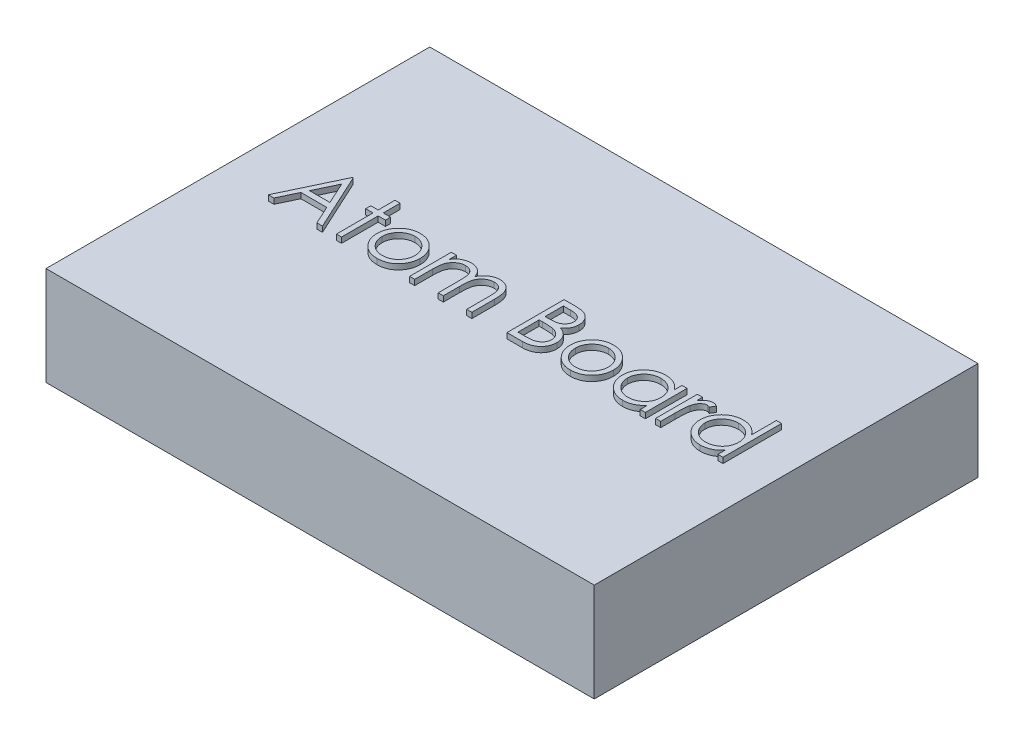
from build123d import *

# Parameters (mm, degrees)
SKETCH1_W           = 254
SKETCH1_H           = 177.8
BOSS_EXTRUDE1_DEPTH = 45.72
BOSS_EXTRUDE2_DEPTH = 2.54


with BuildPart() as part:
    # Sketch1 → Boss-Extrude1 (new body)
    with BuildSketch(Plane(origin=(0, 0, 0), x_dir=(1, 0, 0), z_dir=(0, 1, 0))):
        Rectangle(SKETCH1_W, SKETCH1_H)
    extrude(amount=BOSS_EXTRUDE1_DEPTH)

    # Sketch2 → Boss-Extrude2 (add)
    with BuildSketch(Plane(origin=(0, 45.72, 0), x_dir=(1, 0, 0), z_dir=(0, 1, 0))):
        Polygon((-89.677431312, 16.12080244), (-77.46589285, -10.337530894), (-80.047064392, -10.337530894), (-83.958572805, -1.857295851), (-95.952805244, -1.857295851), (-99.975616742, -10.337530894), (-102.567388577, -10.337530894), (-90.016640714, 16.12080244), align=None)
        Polygon((-89.873536747, 10.963759504), (-94.664869546, 0.856379363), (-85.209407474, 0.856379363), align=None, mode=Mode.SUBTRACT)
        Polygon((-71.020914218, 16.799221243), (-68.646448406, 16.799221243), (-68.646448406, 8.997405004), (-65.254354389, 8.997405004), (-65.254354389, 6.622939192), (-68.646448406, 6.622939192), (-68.646448406, -10.337530894), (-71.020914218, -10.337530894), (-71.020914218, 6.622939192), (-74.413008235, 6.622939192), (-74.413008235, 8.997405004), (-71.020914218, 8.997405004), align=None)
        with BuildLine():
            add(Edge.make_bspline(
                [(-51.844982728, 9.336614406), (-51.482191558, 9.328889395), (-50.770846736, 9.313742538), (-49.729084741, 9.151855595), (-48.734666154, 8.904301114), (-47.78378244, 8.562069663), (-46.888611635, 8.103343013), (-46.03611473, 7.555963253), (-45.228629008, 6.907487694), (-44.744645394, 6.405852296), (-44.498979122, 6.151226118)],
                knots=[0, 0, 0, 0, 0.001087577, 0.002132472, 0.003154425, 0.004158785, 0.005156692, 0.006165239, 0.007194137, 0.008254762, 0.008254762, 0.008254762, 0.008254762], degree=3))
            add(Edge.make_bspline(
                [(-44.498979122, 6.151226118), (-44.287448874, 5.907703725), (-43.868482071, 5.425371769), (-43.331259078, 4.6432966), (-42.868453236, 3.833368458), (-42.497560614, 2.98483212), (-42.205120257, 2.105095022), (-41.997492672, 1.19113339), (-41.873993223, 0.244965647), (-41.857339842, -0.397622891), (-41.848905671, -0.723064414)],
                knots=[0, 0, 0, 0, 0.000967026, 0.001915338, 0.002840969, 0.003761746, 0.004688606, 0.005618204, 0.006569473, 0.007545621, 0.007545621, 0.007545621, 0.007545621], degree=3))
            add(Edge.make_bspline(
                [(-41.848905671, -0.723064414), (-41.856324114, -1.050392231), (-41.870983303, -1.697207262), (-42.009652308, -2.649853659), (-42.225333731, -3.57358833), (-42.534002983, -4.464543932), (-42.929805357, -5.325443877), (-43.412788531, -6.15252797), (-43.986341827, -6.947428025), (-44.636491088, -7.703394302), (-45.355038009, -8.400126997), (-46.134546988, -9.007370464), (-46.959699505, -9.527628416), (-47.841467711, -9.946701319), (-48.771799308, -10.27712584), (-49.752700954, -10.509203345), (-50.782648807, -10.649520835), (-51.485890301, -10.667539514), (-51.844982728, -10.676740295)],
                knots=[0, 0, 0, 0, 0.000981444, 0.001939378, 0.002881702, 0.003823698, 0.004762841, 0.005720057, 0.006692313, 0.007699508, 0.008707832, 0.009689605, 0.010658735, 0.011628329, 0.012612345, 0.013615068, 0.014647237, 0.015724223, 0.015724223, 0.015724223, 0.015724223], degree=3))
            add(Edge.make_bspline(
                [(-51.844982728, -10.676740295), (-52.205834476, -10.667508633), (-52.912580856, -10.649427957), (-53.946164172, -10.509748498), (-54.928823791, -10.277232797), (-55.860373316, -9.945615441), (-56.745932576, -9.527615021), (-57.575866213, -9.00894332), (-58.356008432, -8.399946908), (-59.074707362, -7.703443099), (-59.724815866, -6.947415453), (-60.298379679, -6.152531233), (-60.781360121, -5.325443027), (-61.17716321, -4.464544158), (-61.485832272, -3.573588269), (-61.701513746, -2.649853675), (-61.840182737, -1.697207258), (-61.854841928, -1.050392229), (-61.862260372, -0.723064414)],
                knots=[0, 0, 0, 0, 0.001082282, 0.002119703, 0.003122426, 0.004106442, 0.005080819, 0.006054446, 0.007036219, 0.008044543, 0.009051738, 0.010023994, 0.01098121, 0.011920353, 0.012862349, 0.013804673, 0.014762608, 0.015744051, 0.015744051, 0.015744051, 0.015744051], degree=3))
            add(Edge.make_bspline(
                [(-61.862260372, -0.723064414), (-61.85376868, -0.399391716), (-61.836956591, 0.2414246), (-61.713581314, 1.18581369), (-61.506763655, 2.098228476), (-61.213972741, 2.974569872), (-60.839661477, 3.819387751), (-60.383358883, 4.631317128), (-59.840655887, 5.409855858), (-59.42335542, 5.891564439), (-59.212186921, 6.135325677)],
                knots=[0, 0, 0, 0, 0.000970853, 0.001922123, 0.002851721, 0.00377355, 0.004689479, 0.005619727, 0.006563689, 0.007530715, 0.007530715, 0.007530715, 0.007530715], degree=3))
            add(Edge.make_bspline(
                [(-59.212186921, 6.135325677), (-58.966891024, 6.392160039), (-58.484473482, 6.897270005), (-57.672968219, 7.543855157), (-56.8225685, 8.102625477), (-55.91750507, 8.552237344), (-54.967402513, 8.906314234), (-53.967888001, 9.152494021), (-52.92259095, 9.313159264), (-52.207765243, 9.328718108), (-51.844982728, 9.336614406)],
                knots=[0, 0, 0, 0, 0.001064367, 0.002093264, 0.00310469, 0.004112067, 0.005118257, 0.00614021, 0.007195592, 0.008283169, 0.008283169, 0.008283169, 0.008283169], degree=3))
        make_face()
        with BuildLine():
            add(Edge.make_bspline(
                [(-51.855583021, 6.962148594), (-52.112135202, 6.95485674), (-52.618616711, 6.940461271), (-53.364133809, 6.830969848), (-54.081836163, 6.657497645), (-54.773085402, 6.411026505), (-55.435550455, 6.092778876), (-56.06986558, 5.701888296), (-56.677896525, 5.243532018), (-57.247749028, 4.718427298), (-57.770734364, 4.144818232), (-58.227919068, 3.533643138), (-58.616668384, 2.894815402), (-58.940519585, 2.22767071), (-59.181722733, 1.525448296), (-59.356899749, 0.796100667), (-59.466287876, 0.038141864), (-59.480548, -0.477122977), (-59.48779456, -0.738964855)],
                knots=[0, 0, 0, 0, 0.000769416, 0.00151897, 0.002255557, 0.002981445, 0.003716333, 0.004456269, 0.005213132, 0.005997142, 0.006777579, 0.007538681, 0.008283139, 0.009018027, 0.009758911, 0.010505799, 0.011265848, 0.012051147, 0.012051147, 0.012051147, 0.012051147], degree=3))
            add(Edge.make_bspline(
                [(-59.48779456, -0.738964855), (-59.475647738, -1.077268869), (-59.451538569, -1.748739078), (-59.255480532, -2.737608874), (-58.927500916, -3.686947875), (-58.48460898, -4.591190793), (-57.929692922, -5.427820514), (-57.275891882, -6.173729949), (-56.530222719, -6.817694119), (-55.701574176, -7.352007654), (-54.806871891, -7.776548665), (-53.85999375, -8.077409969), (-52.872412313, -8.272987644), (-52.1974925, -8.292426765), (-51.855583021, -8.302274483)],
                knots=[0, 0, 0, 0, 0.001014324, 0.002013244, 0.003010531, 0.004020303, 0.005025781, 0.006013502, 0.006986782, 0.007971769, 0.008962783, 0.009948354, 0.010946274, 0.011970863, 0.011970863, 0.011970863, 0.011970863], degree=3))
            add(Edge.make_bspline(
                [(-51.855583021, -8.302274483), (-51.513693209, -8.292369388), (-50.838812215, -8.272817006), (-49.852602962, -8.078394976), (-48.908312817, -7.775230398), (-48.014539828, -7.352485121), (-47.186268481, -6.815665081), (-46.435236433, -6.177366278), (-45.787017765, -5.425844902), (-45.232650633, -4.59008263), (-44.782505614, -3.688349731), (-44.456061172, -2.73743366), (-44.259531802, -1.7487837), (-44.235486252, -1.077283819), (-44.223371483, -0.738964855)],
                knots=[0, 0, 0, 0, 0.001024588, 0.002022509, 0.003003036, 0.00399405, 0.004979037, 0.005956336, 0.006940566, 0.007946044, 0.008958164, 0.009955451, 0.010954371, 0.011968695, 0.011968695, 0.011968695, 0.011968695], degree=3))
            add(Edge.make_bspline(
                [(-44.223371483, -0.738964855), (-44.230615548, -0.477121412), (-44.244870762, 0.038146508), (-44.3542946, 0.796082913), (-44.529339453, 1.525513435), (-44.771029655, 2.227430365), (-45.093473689, 2.896542749), (-45.489719684, 3.531767471), (-45.945037554, 4.146935408), (-46.474333647, 4.71657305), (-47.043591325, 5.243736719), (-47.651868697, 5.702066032), (-48.285243237, 6.09106095), (-48.945783714, 6.413748602), (-49.637121576, 6.655255282), (-50.353818326, 6.831971485), (-51.096154568, 6.939998566), (-51.600821145, 6.954718029), (-51.855583021, 6.962148594)],
                knots=[0, 0, 0, 0, 0.000785299, 0.001545348, 0.002292236, 0.00303312, 0.003768008, 0.004515235, 0.005276337, 0.006060346, 0.006844356, 0.00760122, 0.008341156, 0.009071269, 0.009802151, 0.010533591, 0.011283145, 0.012047267, 0.012047267, 0.012047267, 0.012047267], degree=3))
        make_face(mode=Mode.SUBTRACT)
        with BuildLine():
            Line((-37.099974047, 8.997405004), (-34.725508235, 8.997405004))
            Line((-34.725508235, 8.997405004), (-34.725508235, 5.637111868))
            add(Edge.make_bspline(
                [(-34.725508235, 5.637111868), (-34.511695042, 5.931083619), (-34.102008467, 6.494361678), (-33.430226451, 7.236633469), (-32.759121315, 7.866554638), (-32.275815393, 8.197229918), (-32.043633903, 8.356087229)],
                knots=[0, 0, 0, 0, 0.001089718, 0.002088005, 0.002999646, 0.003842519, 0.003842519, 0.003842519, 0.003842519], degree=3))
            add(Edge.make_bspline(
                [(-32.043633903, 8.356087229), (-31.727156992, 8.507318264), (-31.099732393, 8.80713815), (-30.106265633, 9.111284697), (-29.089701167, 9.298194689), (-28.403234312, 9.323756262), (-28.057923433, 9.336614406)],
                knots=[0, 0, 0, 0, 0.001051007, 0.002083652, 0.003106677, 0.00414216, 0.00414216, 0.00414216, 0.00414216], degree=3))
            add(Edge.make_bspline(
                [(-28.057923433, 9.336614406), (-27.82438709, 9.328712505), (-27.362231224, 9.313075069), (-26.677458638, 9.211323612), (-26.01328937, 9.035442424), (-25.373647601, 8.790458486), (-24.770997228, 8.493772222), (-24.218477697, 8.145658359), (-23.722389933, 7.754853086), (-23.282984664, 7.303708772), (-22.887855722, 6.779557104), (-22.524402536, 6.168261889), (-22.188569086, 5.456096832), (-22.002443715, 4.939278338), (-21.90445288, 4.667184985)],
                knots=[0, 0, 0, 0, 0.000700602, 0.001386455, 0.002071672, 0.002757769, 0.003438049, 0.00408358, 0.004713495, 0.005328175, 0.005967387, 0.0066782, 0.007458204, 0.008325438, 0.008325438, 0.008325438, 0.008325438], degree=3))
            add(Edge.make_bspline(
                [(-21.90445288, 4.667184985), (-21.800802349, 4.854089821), (-21.59683266, 5.221892291), (-21.254343618, 5.742427964), (-20.89550968, 6.22931264), (-20.517272738, 6.682932634), (-20.120967826, 7.101047858), (-19.704729859, 7.485040686), (-19.270928238, 7.836560159), (-18.6677369, 8.247217376), (-17.882963023, 8.683410831), (-16.893511204, 9.061602044), (-15.86428074, 9.295313253), (-15.165646949, 9.322756387), (-14.812856325, 9.336614406)],
                knots=[0, 0, 0, 0, 0.000640967, 0.001261334, 0.001867685, 0.002454687, 0.003032038, 0.003594653, 0.004152555, 0.004705322, 0.005782283, 0.006837492, 0.007874006, 0.008931342, 0.008931342, 0.008931342, 0.008931342], degree=3))
            add(Edge.make_bspline(
                [(-14.812856325, 9.336614406), (-14.488692886, 9.324388986), (-13.854273561, 9.300462653), (-12.930671612, 9.112582229), (-12.069325822, 8.78995954), (-11.271969354, 8.349740978), (-10.552606479, 7.796541199), (-9.92731057, 7.138342248), (-9.399879847, 6.3797998), (-9.055327035, 5.666241314), (-8.821622359, 5.036265882), (-8.677528504, 4.499492132), (-8.550228428, 3.908703607), (-8.444536872, 3.263193892), (-8.367289484, 2.560682746), (-8.31005848, 1.802319815), (-8.271322924, 0.987515697), (-8.26858583, 0.425347928), (-8.267174902, 0.135559384)],
                knots=[0, 0, 0, 0, 0.00097201, 0.001902318, 0.002812972, 0.003721588, 0.004624808, 0.005524554, 0.006434653, 0.007385169, 0.007893237, 0.008448742, 0.009050653, 0.009705902, 0.010410024, 0.011170184, 0.011987249, 0.012856538, 0.012856538, 0.012856538, 0.012856538], degree=3))
            Line((-8.267174902, 0.135559384), (-8.267174902, -10.337530894))
            Line((-8.267174902, -10.337530894), (-10.641640714, -10.337530894))
            Line((-10.641640714, -10.337530894), (-10.641640714, 0.146159678))
            add(Edge.make_bspline(
                [(-10.641640714, 0.146159678), (-10.642229472, 0.393511636), (-10.643360976, 0.86888448), (-10.663723548, 1.551150034), (-10.702090505, 2.17305964), (-10.746953548, 2.733765306), (-10.809272821, 3.2345746), (-10.889750996, 3.674481574), (-10.975004885, 4.056946695), (-11.116640056, 4.480930507), (-11.343031856, 4.948639837), (-11.687878283, 5.453038297), (-12.122324919, 5.892101488), (-12.623976103, 6.273239955), (-13.195086369, 6.583132361), (-13.824528026, 6.804445053), (-14.508393178, 6.941445384), (-14.981791638, 6.955098002), (-15.226267784, 6.962148594)],
                knots=[0, 0, 0, 0, 0.000742039, 0.001426087, 0.002047313, 0.00261115, 0.003113407, 0.003560446, 0.003952549, 0.00428776, 0.00489937, 0.005505096, 0.006112281, 0.006744066, 0.00738914, 0.008052993, 0.008739029, 0.009471678, 0.009471678, 0.009471678, 0.009471678], degree=3))
            add(Edge.make_bspline(
                [(-15.226267784, 6.962148594), (-15.526153748, 6.951443118), (-16.118842422, 6.930285029), (-16.9839958, 6.714280156), (-17.815324318, 6.388613975), (-18.588022049, 5.916654329), (-19.298827371, 5.351138721), (-19.910389656, 4.678722134), (-20.415609155, 3.918007806), (-20.757707663, 3.213863092), (-20.973829167, 2.581361939), (-21.116529661, 2.028780615), (-21.227529108, 1.400723524), (-21.331627751, 0.701410945), (-21.399570695, -0.073970776), (-21.4613197, -0.921834879), (-21.490203604, -1.844731477), (-21.494243857, -2.484468944), (-21.496341568, -2.81662244)],
                knots=[0, 0, 0, 0, 0.00089798, 0.00177475, 0.002659557, 0.003567616, 0.004479796, 0.005376461, 0.00628198, 0.007211246, 0.007715763, 0.008285251, 0.008921445, 0.009628275, 0.010405646, 0.011255671, 0.012178445, 0.013174929, 0.013174929, 0.013174929, 0.013174929], degree=3))
            Line((-21.496341568, -2.81662244), (-21.496341568, -10.337530894))
            Line((-21.496341568, -10.337530894), (-23.87080738, -10.337530894))
            Line((-23.87080738, -10.337530894), (-23.87080738, -0.505758391))
            add(Edge.make_bspline(
                [(-23.87080738, -0.505758391), (-23.871407841, -0.228374374), (-23.872563066, 0.305284594), (-23.892794751, 1.070562973), (-23.931247188, 1.76665209), (-23.975701334, 2.392742918), (-24.039656255, 2.947697606), (-24.11230148, 3.434491312), (-24.198091572, 3.851903656), (-24.340134152, 4.309734006), (-24.557201859, 4.814112412), (-24.906363125, 5.351904656), (-25.341849, 5.822621821), (-25.852652645, 6.224476646), (-26.427219409, 6.55665332), (-27.062093927, 6.795985967), (-27.751559637, 6.935264824), (-28.226885152, 6.95301834), (-28.471334891, 6.962148594)],
                knots=[0, 0, 0, 0, 0.00083214, 0.001600954, 0.002296263, 0.002923497, 0.003483635, 0.003971623, 0.00439992, 0.004760369, 0.00540831, 0.006040451, 0.006674367, 0.007323327, 0.00798336, 0.008657667, 0.00934994, 0.010082914, 0.010082914, 0.010082914, 0.010082914], degree=3))
            add(Edge.make_bspline(
                [(-28.471334891, 6.962148594), (-28.758719347, 6.950579045), (-29.331466361, 6.927521345), (-30.172856251, 6.719980108), (-30.985396835, 6.394889781), (-31.756125808, 5.943889958), (-32.464257763, 5.385248114), (-33.084201212, 4.72821289), (-33.605373875, 3.980961267), (-33.951084619, 3.28424141), (-34.174079036, 2.667586296), (-34.322210435, 2.143326156), (-34.449509988, 1.561240946), (-34.544110033, 0.919534809), (-34.635432222, 0.222387252), (-34.679506582, -0.533674664), (-34.722380891, -1.348002351), (-34.724440217, -1.910223378), (-34.725508235, -2.201805399)],
                knots=[0, 0, 0, 0, 0.000860976, 0.001715895, 0.002583971, 0.003479382, 0.004384948, 0.005281049, 0.00617942, 0.007108579, 0.007604872, 0.008145072, 0.008741803, 0.009390979, 0.010090458, 0.01085023, 0.011662001, 0.012536589, 0.012536589, 0.012536589, 0.012536589], degree=3))
            Line((-34.725508235, -2.201805399), (-34.725508235, -10.337530894))
            Line((-34.725508235, -10.337530894), (-37.099974047, -10.337530894))
            Line((-37.099974047, -10.337530894), (-37.099974047, 8.997405004))
        make_face()
        with BuildLine():
            Line((8.01487638, 16.12080244), (13.177219463, 16.12080244))
            add(Edge.make_bspline(
                [(13.177219463, 16.12080244), (13.429922839, 16.11947385), (13.919724876, 16.116898714), (14.63197899, 16.076960758), (15.299097975, 16.022504444), (15.921275302, 15.936098387), (16.498223468, 15.831839119), (17.031681202, 15.705581342), (17.519952147, 15.55418968), (18.102887714, 15.313446958), (18.767526044, 14.955706341), (19.48718056, 14.427079687), (20.102557846, 13.780494996), (20.633132982, 13.051132065), (21.054962874, 12.248796171), (21.360135538, 11.392610637), (21.553340906, 10.493618898), (21.573210617, 9.876435351), (21.583252449, 9.564520722)],
                knots=[0, 0, 0, 0, 0.000757995, 0.001469183, 0.002139542, 0.002765431, 0.003352791, 0.003897857, 0.004409122, 0.004884513, 0.005788044, 0.006666814, 0.007551415, 0.008454682, 0.009365073, 0.010260312, 0.011175044, 0.01210969, 0.01210969, 0.01210969, 0.01210969], degree=3))
            add(Edge.make_bspline(
                [(21.583252449, 9.564520722), (21.574988238, 9.272325807), (21.558748284, 8.698135244), (21.403454806, 7.85831668), (21.160335467, 7.058887823), (20.822385072, 6.302766219), (20.383161648, 5.60703593), (19.862625549, 4.966084573), (19.234604482, 4.407049797), (18.764075227, 4.094517141), (18.525067686, 3.935764713)],
                knots=[0, 0, 0, 0, 0.000875824, 0.001721077, 0.002552643, 0.003378174, 0.0041973, 0.005014365, 0.005847584, 0.006707745, 0.006707745, 0.006707745, 0.006707745], degree=3))
            add(Edge.make_bspline(
                [(18.525067686, 3.935764713), (18.825637586, 3.82036859), (19.400702259, 3.599587221), (20.192078663, 3.209247701), (20.873908741, 2.784688891), (21.451434785, 2.321049309), (21.945356343, 1.82129818), (22.376649413, 1.278107733), (22.74465742, 0.684392123), (23.059987259, 0.046341588), (23.306040355, -0.629528739), (23.490310585, -1.336879248), (23.595897849, -2.073173505), (23.610923471, -2.574259408), (23.618508859, -2.827222734)],
                knots=[0, 0, 0, 0, 0.000965515, 0.001847268, 0.002642803, 0.003370391, 0.004063739, 0.004746636, 0.005446657, 0.006155391, 0.006878099, 0.007600554, 0.008344861, 0.00910369, 0.00910369, 0.00910369, 0.00910369], degree=3))
            add(Edge.make_bspline(
                [(23.618508859, -2.827222734), (23.611124368, -3.085508017), (23.596595176, -3.593691548), (23.489401341, -4.340233339), (23.307903925, -5.053662995), (23.057901807, -5.738595031), (22.731615262, -6.393704381), (22.334528865, -7.019733222), (21.861064069, -7.610391554), (21.331422143, -8.172242753), (20.732238067, -8.677429002), (20.085779681, -9.127339404), (19.383905715, -9.497348326), (18.638143618, -9.808165869), (17.840127657, -10.045589334), (16.99344128, -10.211691529), (16.098814712, -10.323610559), (15.484907665, -10.332812049), (15.170074698, -10.337530894)],
                knots=[0, 0, 0, 0, 0.00077471, 0.001524264, 0.002256989, 0.002979697, 0.003707382, 0.004448437, 0.005199208, 0.005975222, 0.006761093, 0.007546159, 0.008333387, 0.009136565, 0.009966592, 0.010826213, 0.011722926, 0.012666888, 0.012666888, 0.012666888, 0.012666888], degree=3))
            Line((15.170074698, -10.337530894), (8.01487638, -10.337530894))
            Line((8.01487638, -10.337530894), (8.01487638, 16.12080244))
        make_face()
        with BuildLine():
            Line((10.389342192, 13.407127226), (10.389342192, 4.926892183))
            Line((10.389342192, 4.926892183), (11.98468641, 4.926892183))
            add(Edge.make_bspline(
                [(11.98468641, 4.926892183), (12.217888613, 4.929915411), (12.668482793, 4.935756902), (13.321020106, 4.952490037), (13.926727089, 4.999344294), (14.484558208, 5.046185085), (14.993635017, 5.12234417), (15.452829684, 5.212998909), (15.869348839, 5.308875632), (16.349677547, 5.471930682), (16.894514717, 5.712910726), (17.475336397, 6.086894249), (17.987376732, 6.5323343), (18.419760235, 7.046313594), (18.773632661, 7.612266309), (19.019420865, 8.221162369), (19.186087834, 8.857826463), (19.201142863, 9.294904921), (19.208786637, 9.5168194)],
                knots=[0, 0, 0, 0, 0.0006997, 0.001351962, 0.001957665, 0.002521975, 0.003030927, 0.003500761, 0.003926261, 0.004311753, 0.005021042, 0.005707631, 0.006376249, 0.007049451, 0.007715774, 0.008369328, 0.009013356, 0.009677589, 0.009677589, 0.009677589, 0.009677589], degree=3))
            add(Edge.make_bspline(
                [(19.208786637, 9.5168194), (19.204808965, 9.663668983), (19.197006328, 9.951730474), (19.133103386, 10.371657139), (19.024491365, 10.76659503), (18.884985695, 11.14195646), (18.690035489, 11.486004375), (18.460502165, 11.810634485), (18.183175816, 12.104791572), (17.867510417, 12.37972766), (17.504588089, 12.623480936), (17.094625348, 12.836967657), (16.632075646, 13.0088771), (16.124734421, 13.159433729), (15.564792271, 13.265178569), (14.958710826, 13.35327263), (14.301525747, 13.398121335), (13.846857413, 13.404058304), (13.611831509, 13.407127226)],
                knots=[0, 0, 0, 0, 0.000440423, 0.000863937, 0.00127022, 0.001667873, 0.002061692, 0.002452935, 0.002857971, 0.003271315, 0.003706444, 0.004166336, 0.004654554, 0.005184569, 0.005752106, 0.006362244, 0.007021192, 0.00772629, 0.00772629, 0.00772629, 0.00772629], degree=3))
            Line((13.611831509, 13.407127226), (10.389342192, 13.407127226))
        make_face(mode=Mode.SUBTRACT)
        with BuildLine():
            Line((10.389342192, 2.21321697), (10.389342192, -7.62385568))
            Line((10.389342192, -7.62385568), (13.770835916, -7.62385568))
            add(Edge.make_bspline(
                [(13.770835916, -7.62385568), (14.012883748, -7.620954732), (14.479399036, -7.615363538), (15.152961907, -7.597110656), (15.777250846, -7.555591667), (16.349417111, -7.49023316), (16.875638985, -7.41933655), (17.349603764, -7.324001272), (17.7751535, -7.214774011), (18.268596183, -7.045938304), (18.824247704, -6.783649506), (19.423044059, -6.388178866), (19.955432732, -5.917044337), (20.407532013, -5.371768974), (20.778046867, -4.778865491), (21.047585128, -4.150326238), (21.213825533, -3.496536834), (21.233950265, -3.050776567), (21.244043047, -2.827222734)],
                knots=[0, 0, 0, 0, 0.000726197, 0.00139965, 0.002021215, 0.002602422, 0.003127109, 0.003613569, 0.004051946, 0.004444157, 0.005176767, 0.005888251, 0.006590296, 0.007301484, 0.008006005, 0.008680374, 0.009346255, 0.010016173, 0.010016173, 0.010016173, 0.010016173], degree=3))
            add(Edge.make_bspline(
                [(21.244043047, -2.827222734), (21.24195583, -2.687421886), (21.237815062, -2.41007519), (21.175368747, -2.002497271), (21.084549612, -1.607694539), (20.967139368, -1.224594953), (20.796146968, -0.860124786), (20.596526062, -0.507075676), (20.362472609, -0.16498092), (19.997769689, 0.267516472), (19.467302901, 0.7658177), (18.713567158, 1.253690485), (17.856526572, 1.647147122), (17.234925882, 1.81420864), (16.913823028, 1.900508303)],
                knots=[0, 0, 0, 0, 0.000419013, 0.000831268, 0.001233696, 0.001634304, 0.002030399, 0.002438648, 0.002850289, 0.003271709, 0.004134217, 0.005022114, 0.005954232, 0.006950265, 0.006950265, 0.006950265, 0.006950265], degree=3))
            add(Edge.make_bspline(
                [(16.913823028, 1.900508303), (16.785091173, 1.926627092), (16.505973957, 1.983258015), (16.050833319, 2.043036487), (15.531222882, 2.096293785), (14.945942798, 2.135687655), (14.29425257, 2.17640736), (13.574760387, 2.19224321), (12.790404497, 2.211136426), (12.246176443, 2.212505714), (11.963485822, 2.21321697)],
                knots=[0, 0, 0, 0, 0.000393962, 0.00085419, 0.001376302, 0.001960858, 0.002613831, 0.003334962, 0.004119545, 0.004967585, 0.004967585, 0.004967585, 0.004967585], degree=3))
            Line((11.963485822, 2.21321697), (10.389342192, 2.21321697))
        make_face(mode=Mode.SUBTRACT)
        with BuildLine():
            add(Edge.make_bspline(
                [(37.706299324, 9.336614406), (38.069090493, 9.328889395), (38.780435316, 9.313742538), (39.82219731, 9.151855595), (40.816615897, 8.904301114), (41.767499612, 8.562069663), (42.662670417, 8.103343013), (43.515167321, 7.555963253), (44.322653043, 6.907487694), (44.806636657, 6.405852296), (45.052302929, 6.151226118)],
                knots=[0, 0, 0, 0, 0.001087577, 0.002132472, 0.003154425, 0.004158785, 0.005156692, 0.006165239, 0.007194137, 0.008254762, 0.008254762, 0.008254762, 0.008254762], degree=3))
            add(Edge.make_bspline(
                [(45.052302929, 6.151226118), (45.263833177, 5.907703725), (45.68279998, 5.425371769), (46.220022974, 4.6432966), (46.682828815, 3.833368458), (47.053721437, 2.98483212), (47.346161795, 2.105095022), (47.55378938, 1.19113339), (47.677288828, 0.244965647), (47.693942209, -0.397622891), (47.70237638, -0.723064414)],
                knots=[0, 0, 0, 0, 0.000967026, 0.001915338, 0.002840969, 0.003761746, 0.004688606, 0.005618204, 0.006569473, 0.007545621, 0.007545621, 0.007545621, 0.007545621], degree=3))
            add(Edge.make_bspline(
                [(47.70237638, -0.723064414), (47.694957938, -1.050392231), (47.680298749, -1.697207262), (47.541629744, -2.649853659), (47.325948321, -3.57358833), (47.017279068, -4.464543932), (46.621476694, -5.325443877), (46.138493521, -6.15252797), (45.564940224, -6.947428025), (44.914790963, -7.703394302), (44.196244042, -8.400126997), (43.416735064, -9.007370464), (42.591582547, -9.527628416), (41.70981434, -9.946701319), (40.779482744, -10.27712584), (39.798581098, -10.509203345), (38.768633245, -10.649520835), (38.06539175, -10.667539514), (37.706299324, -10.676740295)],
                knots=[0, 0, 0, 0, 0.000981444, 0.001939378, 0.002881702, 0.003823698, 0.004762841, 0.005720057, 0.006692313, 0.007699508, 0.008707832, 0.009689605, 0.010658735, 0.011628329, 0.012612345, 0.013615068, 0.014647237, 0.015724223, 0.015724223, 0.015724223, 0.015724223], degree=3))
            add(Edge.make_bspline(
                [(37.706299324, -10.676740295), (37.345447575, -10.667508633), (36.638701195, -10.649427957), (35.605117879, -10.509748498), (34.62245826, -10.277232797), (33.690908735, -9.945615441), (32.805349476, -9.527615021), (31.975415838, -9.00894332), (31.19527362, -8.399946908), (30.47657469, -7.703443099), (29.826466185, -6.947415453), (29.252902372, -6.152531233), (28.76992193, -5.325443027), (28.374118841, -4.464544158), (28.06544978, -3.573588269), (27.849768305, -2.649853675), (27.711099314, -1.697207258), (27.696440123, -1.050392229), (27.689021679, -0.723064414)],
                knots=[0, 0, 0, 0, 0.001082282, 0.002119703, 0.003122426, 0.004106442, 0.005080819, 0.006054446, 0.007036219, 0.008044543, 0.009051738, 0.010023994, 0.01098121, 0.011920353, 0.012862349, 0.013804673, 0.014762608, 0.015744051, 0.015744051, 0.015744051, 0.015744051], degree=3))
            add(Edge.make_bspline(
                [(27.689021679, -0.723064414), (27.697513371, -0.399391716), (27.71432546, 0.2414246), (27.837700737, 1.18581369), (28.044518396, 2.098228476), (28.33730931, 2.974569872), (28.711620575, 3.819387751), (29.167923168, 4.631317128), (29.710626164, 5.409855858), (30.127926631, 5.891564439), (30.33909513, 6.135325677)],
                knots=[0, 0, 0, 0, 0.000970853, 0.001922123, 0.002851721, 0.00377355, 0.004689479, 0.005619727, 0.006563689, 0.007530715, 0.007530715, 0.007530715, 0.007530715], degree=3))
            add(Edge.make_bspline(
                [(30.33909513, 6.135325677), (30.584391027, 6.392160039), (31.066808569, 6.897270005), (31.878313832, 7.543855157), (32.728713551, 8.102625477), (33.633776981, 8.552237344), (34.583879538, 8.906314234), (35.58339405, 9.152494021), (36.628691102, 9.313159264), (37.343516809, 9.328718108), (37.706299324, 9.336614406)],
                knots=[0, 0, 0, 0, 0.001064367, 0.002093264, 0.00310469, 0.004112067, 0.005118257, 0.00614021, 0.007195592, 0.008283169, 0.008283169, 0.008283169, 0.008283169], degree=3))
        make_face()
        with BuildLine():
            add(Edge.make_bspline(
                [(37.69569903, 6.962148594), (37.439146849, 6.95485674), (36.932665341, 6.940461271), (36.187148242, 6.830969848), (35.469445888, 6.657497645), (34.77819665, 6.411026505), (34.115731596, 6.092778876), (33.481416471, 5.701888296), (32.873385526, 5.243532018), (32.303533023, 4.718427298), (31.780547688, 4.144818232), (31.323362983, 3.533643138), (30.934613667, 2.894815402), (30.610762466, 2.22767071), (30.369559318, 1.525448296), (30.194382303, 0.796100667), (30.084994175, 0.038141864), (30.070734051, -0.477122977), (30.063487491, -0.738964855)],
                knots=[0, 0, 0, 0, 0.000769416, 0.00151897, 0.002255557, 0.002981445, 0.003716333, 0.004456269, 0.005213132, 0.005997142, 0.006777579, 0.007538681, 0.008283139, 0.009018027, 0.009758911, 0.010505799, 0.011265848, 0.012051147, 0.012051147, 0.012051147, 0.012051147], degree=3))
            add(Edge.make_bspline(
                [(30.063487491, -0.738964855), (30.075634313, -1.077268869), (30.099743482, -1.748739078), (30.29580152, -2.737608874), (30.623781135, -3.686947875), (31.066673071, -4.591190793), (31.621589129, -5.427820514), (32.275390169, -6.173729949), (33.021059332, -6.817694119), (33.849707876, -7.352007654), (34.74441016, -7.776548665), (35.691288302, -8.077409969), (36.678869739, -8.272987644), (37.353789551, -8.292426765), (37.69569903, -8.302274483)],
                knots=[0, 0, 0, 0, 0.001014324, 0.002013244, 0.003010531, 0.004020303, 0.005025781, 0.006013502, 0.006986782, 0.007971769, 0.008962783, 0.009948354, 0.010946274, 0.011970863, 0.011970863, 0.011970863, 0.011970863], degree=3))
            add(Edge.make_bspline(
                [(37.69569903, -8.302274483), (38.037588843, -8.292369388), (38.712469836, -8.272817006), (39.69867909, -8.078394976), (40.642969234, -7.775230398), (41.536742223, -7.352485121), (42.36501357, -6.815665081), (43.116045618, -6.177366278), (43.764264286, -5.425844902), (44.318631418, -4.59008263), (44.768776438, -3.688349731), (45.09522088, -2.73743366), (45.291750249, -1.7487837), (45.3157958, -1.077283819), (45.327910568, -0.738964855)],
                knots=[0, 0, 0, 0, 0.001024588, 0.002022509, 0.003003036, 0.00399405, 0.004979037, 0.005956336, 0.006940566, 0.007946044, 0.008958164, 0.009955451, 0.010954371, 0.011968695, 0.011968695, 0.011968695, 0.011968695], degree=3))
            add(Edge.make_bspline(
                [(45.327910568, -0.738964855), (45.320666503, -0.477121412), (45.306411289, 0.038146508), (45.196987451, 0.796082913), (45.021942598, 1.525513435), (44.780252396, 2.227430365), (44.457808363, 2.896542749), (44.061562367, 3.531767471), (43.606244497, 4.146935408), (43.076948404, 4.71657305), (42.507690726, 5.243736719), (41.899413354, 5.702066032), (41.266038814, 6.09106095), (40.605498338, 6.413748602), (39.914160475, 6.655255282), (39.197463725, 6.831971485), (38.455127483, 6.939998566), (37.950460907, 6.954718029), (37.69569903, 6.962148594)],
                knots=[0, 0, 0, 0, 0.000785299, 0.001545348, 0.002292236, 0.00303312, 0.003768008, 0.004515235, 0.005276337, 0.006060346, 0.006844356, 0.00760122, 0.008341156, 0.009071269, 0.009802151, 0.010533591, 0.011283145, 0.012047267, 0.012047267, 0.012047267, 0.012047267], degree=3))
        make_face(mode=Mode.SUBTRACT)
        with BuildLine():
            Line((72.125453303, 8.997405004), (72.125453303, -10.337530894))
            Line((72.125453303, -10.337530894), (69.750987491, -10.337530894))
            Line((69.750987491, -10.337530894), (69.750987491, -6.993138199))
            add(Edge.make_bspline(
                [(69.750987491, -6.993138199), (69.4832383, -7.295818462), (68.960722387, -7.886502803), (68.088042507, -8.658195417), (67.162997353, -9.296055348), (66.190076652, -9.811236258), (65.170158979, -10.198223827), (64.105505224, -10.473285863), (62.995681095, -10.650132117), (62.237821032, -10.66779133), (61.853768608, -10.676740295)],
                knots=[0, 0, 0, 0, 0.00121151, 0.002364276, 0.003484552, 0.004575147, 0.005658894, 0.006749038, 0.007869678, 0.00902103, 0.00902103, 0.00902103, 0.00902103], degree=3))
            add(Edge.make_bspline(
                [(61.853768608, -10.676740295), (61.512320385, -10.667469505), (60.838969372, -10.649187096), (59.848451944, -10.507353015), (58.895254582, -10.279579863), (57.978476563, -9.962829091), (57.104050225, -9.542664547), (56.26448878, -9.039644398), (55.464141644, -8.440621456), (54.715207986, -7.755819099), (54.025537507, -7.011999851), (53.420312411, -6.21866149), (52.915690914, -5.37923455), (52.493717685, -4.504347018), (52.168685795, -3.587263995), (51.942099394, -2.631156833), (51.80043054, -1.637156003), (51.782155689, -0.960279846), (51.772889201, -0.617061476)],
                knots=[0, 0, 0, 0, 0.00102404, 0.002019452, 0.002995169, 0.003960669, 0.004923196, 0.005900337, 0.006892527, 0.007916827, 0.008940799, 0.00993194, 0.010904543, 0.011874136, 0.012841395, 0.013817112, 0.014817773, 0.015847108, 0.015847108, 0.015847108, 0.015847108], degree=3))
            add(Edge.make_bspline(
                [(51.772889201, -0.617061476), (51.782361068, -0.28093705), (51.801086438, 0.383562807), (51.940583993, 1.360848203), (52.175163642, 2.302146959), (52.504364633, 3.204428614), (52.926503221, 4.068784945), (53.440007212, 4.895827277), (54.04491369, 5.687834032), (54.742297958, 6.426181996), (55.497757232, 7.108206878), (56.305936329, 7.700941924), (57.146731372, 8.212849055), (58.033183892, 8.618443786), (58.952173316, 8.946595946), (59.911880912, 9.173630883), (60.908313679, 9.307414204), (61.584819184, 9.326787481), (61.927970665, 9.336614406)],
                knots=[0, 0, 0, 0, 0.001008157, 0.001993072, 0.002954607, 0.003913685, 0.004868962, 0.005835291, 0.006829644, 0.007853341, 0.008878025, 0.009878729, 0.01085587, 0.011825739, 0.012797994, 0.013778865, 0.014778811, 0.015808145, 0.015808145, 0.015808145, 0.015808145], degree=3))
            add(Edge.make_bspline(
                [(61.927970665, 9.336614406), (62.322576742, 9.325745689), (63.096380636, 9.304432648), (64.228253087, 9.127065602), (65.29901789, 8.827417665), (66.31694067, 8.419827055), (67.278366095, 7.878196782), (68.174192226, 7.194967315), (69.013794392, 6.374447628), (69.50047874, 5.744206768), (69.750987491, 5.419805845)],
                knots=[0, 0, 0, 0, 0.00118337, 0.002320532, 0.003426436, 0.004513017, 0.005602349, 0.006725993, 0.007884108, 0.009112508, 0.009112508, 0.009112508, 0.009112508], degree=3))
            Line((69.750987491, 5.419805845), (69.750987491, 8.997405004))
            Line((69.750987491, 8.997405004), (72.125453303, 8.997405004))
        make_face()
        with BuildLine():
            add(Edge.make_bspline(
                [(61.959771546, 6.962148594), (61.612681016, 6.94979907), (60.927579516, 6.925423076), (59.921830215, 6.735123439), (58.959401429, 6.418495851), (58.045106701, 5.985471955), (57.193388635, 5.440969006), (56.432192433, 4.782372835), (55.75529225, 4.027652549), (55.185997634, 3.180213976), (54.721914711, 2.271724836), (54.395592505, 1.322063905), (54.180378551, 0.34835961), (54.158391521, -0.312060693), (54.147355013, -0.64356221)],
                knots=[0, 0, 0, 0, 0.001040774, 0.002054322, 0.003058291, 0.004073003, 0.00508155, 0.00608127, 0.007083503, 0.008113996, 0.009135606, 0.010134624, 0.011120052, 0.012113218, 0.012113218, 0.012113218, 0.012113218], degree=3))
            add(Edge.make_bspline(
                [(54.147355013, -0.64356221), (54.161452718, -0.973082663), (54.189592871, -1.630831961), (54.391815382, -2.605863702), (54.731085854, -3.555748425), (55.194046685, -4.472423792), (55.773761051, -5.323505979), (56.445716936, -6.092612858), (57.216412515, -6.753992484), (58.070090693, -7.307633665), (58.981829517, -7.754874151), (59.940633642, -8.066066783), (60.92847924, -8.266982148), (61.600160573, -8.290450515), (61.938570958, -8.302274483)],
                knots=[0, 0, 0, 0, 0.000988232, 0.001972591, 0.002973365, 0.004006826, 0.00504468, 0.006054842, 0.007062037, 0.008080796, 0.009100093, 0.010099027, 0.011097946, 0.01211227, 0.01211227, 0.01211227, 0.01211227], degree=3))
            add(Edge.make_bspline(
                [(61.938570958, -8.302274483), (62.282124878, -8.289725946), (62.96541955, -8.264768151), (63.974152639, -8.073653824), (64.953072894, -7.757901599), (65.888845394, -7.320211772), (66.760580433, -6.777760331), (67.542975103, -6.142706726), (68.20455415, -5.40411718), (68.765414948, -4.592402326), (69.205193396, -3.702555687), (69.525536224, -2.755088887), (69.714931822, -1.749968946), (69.738802754, -1.063080927), (69.750987491, -0.71246412)],
                knots=[0, 0, 0, 0, 0.001030194, 0.002048953, 0.003068043, 0.004108993, 0.005139922, 0.00614158, 0.007120961, 0.008104477, 0.009092894, 0.010088476, 0.011096814, 0.012148168, 0.012148168, 0.012148168, 0.012148168], degree=3))
            add(Edge.make_bspline(
                [(69.750987491, -0.71246412), (69.743732946, -0.445326949), (69.729453706, 0.080483541), (69.620365472, 0.852518942), (69.446837159, 1.591339371), (69.202315516, 2.297721604), (68.88110164, 2.967760113), (68.493692934, 3.606265919), (68.033276736, 4.209918172), (67.507264689, 4.770404482), (66.931492026, 5.281628334), (66.322235678, 5.737953249), (65.672277293, 6.112820757), (64.992547311, 6.423073226), (64.28186639, 6.669960847), (63.534451586, 6.834665437), (62.758247339, 6.94775834), (62.228732516, 6.957301338), (61.959771546, 6.962148594)],
                knots=[0, 0, 0, 0, 0.000801182, 0.001576979, 0.002334177, 0.003075061, 0.003814731, 0.004559189, 0.005311829, 0.00608806, 0.00686141, 0.007619349, 0.008367496, 0.009107489, 0.009858391, 0.010619548, 0.011400596, 0.012206846, 0.012206846, 0.012206846, 0.012206846], degree=3))
        make_face(mode=Mode.SUBTRACT)
        with BuildLine():
            Line((76.874384927, 8.997405004), (79.248850739, 8.997405004))
            Line((79.248850739, 8.997405004), (79.248850739, 6.151226118))
            add(Edge.make_bspline(
                [(79.248850739, 6.151226118), (79.424146713, 6.416231487), (79.759398901, 6.923052196), (80.316633546, 7.593349888), (80.887402776, 8.14833268), (81.474439014, 8.590591423), (82.082059174, 8.921797738), (82.696927797, 9.164405801), (83.328718551, 9.307865267), (83.753275954, 9.327018522), (83.965981482, 9.336614406)],
                knots=[0, 0, 0, 0, 0.000952671, 0.001821976, 0.00260915, 0.003336334, 0.004019477, 0.004678935, 0.00531418, 0.005951984, 0.005951984, 0.005951984, 0.005951984], degree=3))
            add(Edge.make_bspline(
                [(83.965981482, 9.336614406), (84.130978117, 9.327614591), (84.470469415, 9.309096889), (84.984385422, 9.17899125), (85.513880564, 8.971270485), (85.855135515, 8.775930706), (86.033038774, 8.674096043)],
                knots=[0, 0, 0, 0, 0.000494734, 0.001017947, 0.001581909, 0.002196109, 0.002196109, 0.002196109, 0.002196109], degree=3))
            Line((86.033038774, 8.674096043), (84.729202636, 6.617639045))
            add(Edge.make_bspline(
                [(84.729202636, 6.617639045), (84.614985631, 6.668592247), (84.39817989, 6.765311179), (84.081023347, 6.879777565), (83.788610861, 6.947177643), (83.602317295, 6.957388424), (83.515468995, 6.962148594)],
                knots=[0, 0, 0, 0, 0.000375114, 0.000712038, 0.001010404, 0.001270975, 0.001270975, 0.001270975, 0.001270975], degree=3))
            add(Edge.make_bspline(
                [(83.515468995, 6.962148594), (83.324925653, 6.949448311), (82.936272467, 6.923543416), (82.365645596, 6.719898858), (81.811931602, 6.390868769), (81.372181536, 6.025962149), (81.031683553, 5.674082966), (80.788718752, 5.366800399), (80.565843225, 5.022247649), (80.352889773, 4.64631492), (80.158864811, 4.232583346), (79.977778919, 3.785186435), (79.814048229, 3.303605997), (79.720686263, 2.968095279), (79.672862491, 2.796233129)],
                knots=[0, 0, 0, 0, 0.000570671, 0.001164003, 0.001795789, 0.002496131, 0.002870983, 0.003263337, 0.003669066, 0.004100988, 0.004558553, 0.005038853, 0.005548385, 0.006083489, 0.006083489, 0.006083489, 0.006083489], degree=3))
            add(Edge.make_bspline(
                [(79.672862491, 2.796233129), (79.637087851, 2.642947352), (79.557849741, 2.303431006), (79.480806568, 1.733832039), (79.404685807, 1.060855571), (79.351038752, 0.282628351), (79.301311886, -0.598906195), (79.273265431, -1.585091023), (79.249807166, -2.676938379), (79.24917922, -3.440256407), (79.248850739, -3.839550792)],
                knots=[0, 0, 0, 0, 0.000471981, 0.001045402, 0.001722598, 0.002503898, 0.003385015, 0.004371355, 0.005463391, 0.006661236, 0.006661236, 0.006661236, 0.006661236], degree=3))
            Line((79.248850739, -3.839550792), (79.248850739, -10.337530894))
            Line((79.248850739, -10.337530894), (76.874384927, -10.337530894))
            Line((76.874384927, -10.337530894), (76.874384927, 8.997405004))
        make_face()
        with BuildLine():
            Line((108.081649885, 16.799221243), (108.081649885, -10.337530894))
            Line((108.081649885, -10.337530894), (105.707184073, -10.337530894))
            Line((105.707184073, -10.337530894), (105.707184073, -6.993138199))
            add(Edge.make_bspline(
                [(105.707184073, -6.993138199), (105.439434882, -7.295818462), (104.916918968, -7.886502803), (104.044239089, -8.658195417), (103.119193934, -9.296055348), (102.146273233, -9.811236258), (101.12635556, -10.198223827), (100.061701805, -10.473285863), (98.951877676, -10.650132117), (98.194017613, -10.66779133), (97.809965189, -10.676740295)],
                knots=[0, 0, 0, 0, 0.00121151, 0.002364276, 0.003484552, 0.004575147, 0.005658894, 0.006749038, 0.007869678, 0.00902103, 0.00902103, 0.00902103, 0.00902103], degree=3))
            add(Edge.make_bspline(
                [(97.809965189, -10.676740295), (97.468516967, -10.667469505), (96.795165954, -10.649187096), (95.804648525, -10.507353015), (94.851451163, -10.279579863), (93.934673144, -9.962829091), (93.060246806, -9.542664547), (92.220685361, -9.039644398), (91.420338225, -8.440621456), (90.671404567, -7.755819099), (89.981734088, -7.011999851), (89.376508992, -6.21866149), (88.871887495, -5.37923455), (88.449914266, -4.504347018), (88.124882377, -3.587263995), (87.898295975, -2.631156833), (87.756627122, -1.637156003), (87.73835227, -0.960279846), (87.729085782, -0.617061476)],
                knots=[0, 0, 0, 0, 0.00102404, 0.002019452, 0.002995169, 0.003960669, 0.004923196, 0.005900337, 0.006892527, 0.007916827, 0.008940799, 0.00993194, 0.010904543, 0.011874136, 0.012841395, 0.013817112, 0.014817773, 0.015847108, 0.015847108, 0.015847108, 0.015847108], degree=3))
            add(Edge.make_bspline(
                [(87.729085782, -0.617061476), (87.738557649, -0.28093705), (87.757283019, 0.383562807), (87.896780574, 1.360848203), (88.131360223, 2.302146959), (88.460561214, 3.204428614), (88.882699802, 4.068784945), (89.396203793, 4.895827277), (90.001110272, 5.687834032), (90.698494539, 6.426181996), (91.453953813, 7.108206878), (92.26213291, 7.700941924), (93.102927954, 8.212849055), (93.989380474, 8.618443786), (94.908369897, 8.946595946), (95.868077493, 9.173630883), (96.86451026, 9.307414204), (97.541015766, 9.326787481), (97.884167246, 9.336614406)],
                knots=[0, 0, 0, 0, 0.001008157, 0.001993072, 0.002954607, 0.003913685, 0.004868962, 0.005835291, 0.006829644, 0.007853341, 0.008878025, 0.009878729, 0.01085587, 0.011825739, 0.012797994, 0.013778865, 0.014778811, 0.015808145, 0.015808145, 0.015808145, 0.015808145], degree=3))
            add(Edge.make_bspline(
                [(97.884167246, 9.336614406), (98.278901447, 9.324767906), (99.053720817, 9.301514543), (100.186882259, 9.10718665), (101.258729077, 8.780895847), (102.275432018, 8.334193899), (103.230929824, 7.753616791), (104.132226453, 7.052460013), (104.963648001, 6.210879802), (105.455559993, 5.578816121), (105.707184073, 5.255501291)],
                knots=[0, 0, 0, 0, 0.001183643, 0.002323359, 0.003436668, 0.004537721, 0.005645756, 0.006782326, 0.007955384, 0.009183784, 0.009183784, 0.009183784, 0.009183784], degree=3))
            Line((105.707184073, 5.255501291), (105.707184073, 16.799221243))
            Line((105.707184073, 16.799221243), (108.081649885, 16.799221243))
        make_face()
        with BuildLine():
            add(Edge.make_bspline(
                [(97.915968127, 6.962148594), (97.568877597, 6.94979907), (96.883776097, 6.925423076), (95.878026796, 6.735123439), (94.915598011, 6.418495851), (94.001303283, 5.985471955), (93.149585216, 5.440969006), (92.388389014, 4.782372835), (91.711488831, 4.027652549), (91.142194215, 3.180213976), (90.678111292, 2.271724836), (90.351789086, 1.322063905), (90.136575132, 0.34835961), (90.114588102, -0.312060693), (90.103551594, -0.64356221)],
                knots=[0, 0, 0, 0, 0.001040774, 0.002054322, 0.003058291, 0.004073003, 0.00508155, 0.00608127, 0.007083503, 0.008113996, 0.009135606, 0.010134624, 0.011120052, 0.012113218, 0.012113218, 0.012113218, 0.012113218], degree=3))
            add(Edge.make_bspline(
                [(90.103551594, -0.64356221), (90.117649299, -0.973082663), (90.145789452, -1.630831961), (90.348011963, -2.605863702), (90.687282435, -3.555748425), (91.150243266, -4.472423792), (91.729957632, -5.323505979), (92.401913517, -6.092612858), (93.172609096, -6.753992484), (94.026287275, -7.307633665), (94.938026098, -7.754874151), (95.896830223, -8.066066783), (96.884675821, -8.266982148), (97.556357155, -8.290450515), (97.89476754, -8.302274483)],
                knots=[0, 0, 0, 0, 0.000988232, 0.001972591, 0.002973365, 0.004006826, 0.00504468, 0.006054842, 0.007062037, 0.008080796, 0.009100093, 0.010099027, 0.011097946, 0.01211227, 0.01211227, 0.01211227, 0.01211227], degree=3))
            add(Edge.make_bspline(
                [(97.89476754, -8.302274483), (98.238321459, -8.289725946), (98.921616131, -8.264768151), (99.93034922, -8.073653824), (100.909269475, -7.757901599), (101.845041975, -7.320211772), (102.716777014, -6.777760331), (103.499171684, -6.142706726), (104.160750731, -5.40411718), (104.72161153, -4.592402326), (105.161389977, -3.702555687), (105.481732806, -2.755088887), (105.671128403, -1.749968946), (105.694999335, -1.063080927), (105.707184073, -0.71246412)],
                knots=[0, 0, 0, 0, 0.001030194, 0.002048953, 0.003068043, 0.004108993, 0.005139922, 0.00614158, 0.007120961, 0.008104477, 0.009092894, 0.010088476, 0.011096814, 0.012148168, 0.012148168, 0.012148168, 0.012148168], degree=3))
            add(Edge.make_bspline(
                [(105.707184073, -0.71246412), (105.699929527, -0.445326949), (105.685650287, 0.080483541), (105.576562053, 0.852518942), (105.40303374, 1.591339371), (105.158512098, 2.297721604), (104.837298221, 2.967760113), (104.449889515, 3.606265919), (103.989473318, 4.209918172), (103.46346127, 4.770404482), (102.887688608, 5.281628334), (102.278432259, 5.737953249), (101.628473874, 6.112820757), (100.948743893, 6.423073226), (100.238062971, 6.669960847), (99.490648167, 6.834665437), (98.71444392, 6.94775834), (98.184929097, 6.957301338), (97.915968127, 6.962148594)],
                knots=[0, 0, 0, 0, 0.000801182, 0.001576979, 0.002334177, 0.003075061, 0.003814731, 0.004559189, 0.005311829, 0.00608806, 0.00686141, 0.007619349, 0.008367496, 0.009107489, 0.009858391, 0.010619548, 0.011400596, 0.012206846, 0.012206846, 0.012206846, 0.012206846], degree=3))
        make_face(mode=Mode.SUBTRACT)
    extrude(amount=BOSS_EXTRUDE2_DEPTH)


solid = part.part
